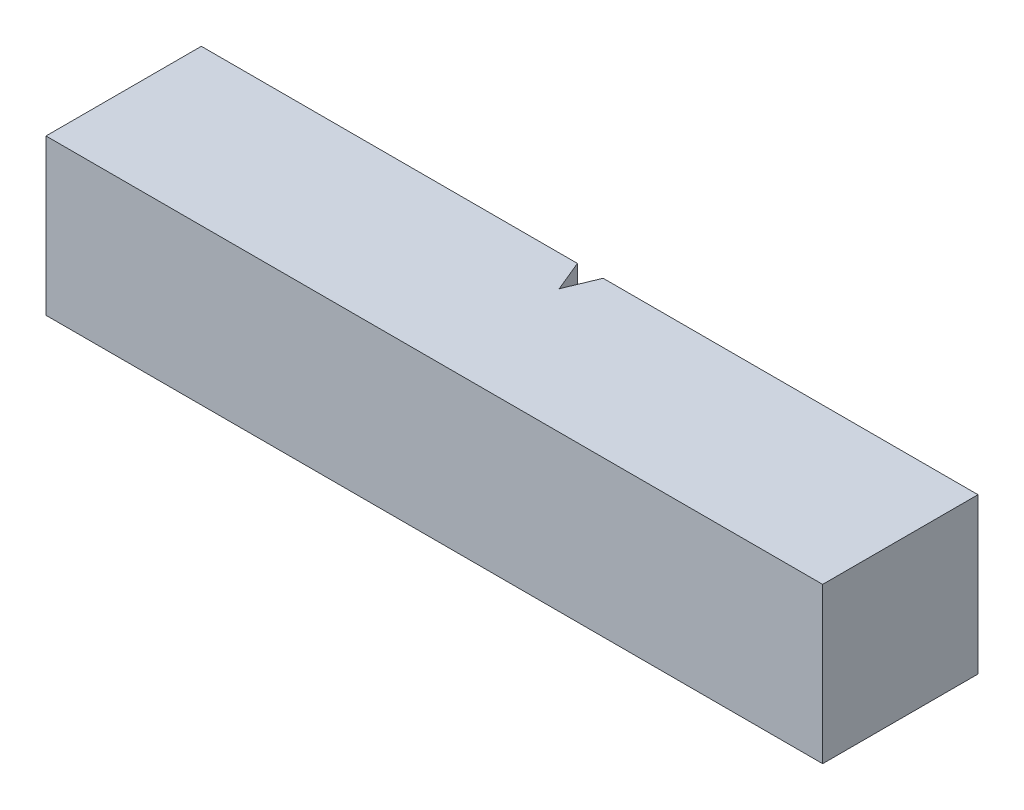
from build123d import *

# Parameters (mm, degrees)
BOSS_EXTRUDE1_DEPTH = 12.7


with BuildPart() as part:
    # Sketch1 → Boss-Extrude1 (new body)
    with BuildSketch(Plane(origin=(0, 0, 0), x_dir=(1, 0, 0), z_dir=(0, 1, 0))):
        Polygon((-63.5, 0), (0, 0), (0, 12.7), (-30.647897652, 12.7), (-31.7000001, 10.16), (-32.752102548, 12.7), (-63.5, 12.7), align=None)
    extrude(amount=BOSS_EXTRUDE1_DEPTH)


solid = part.part
